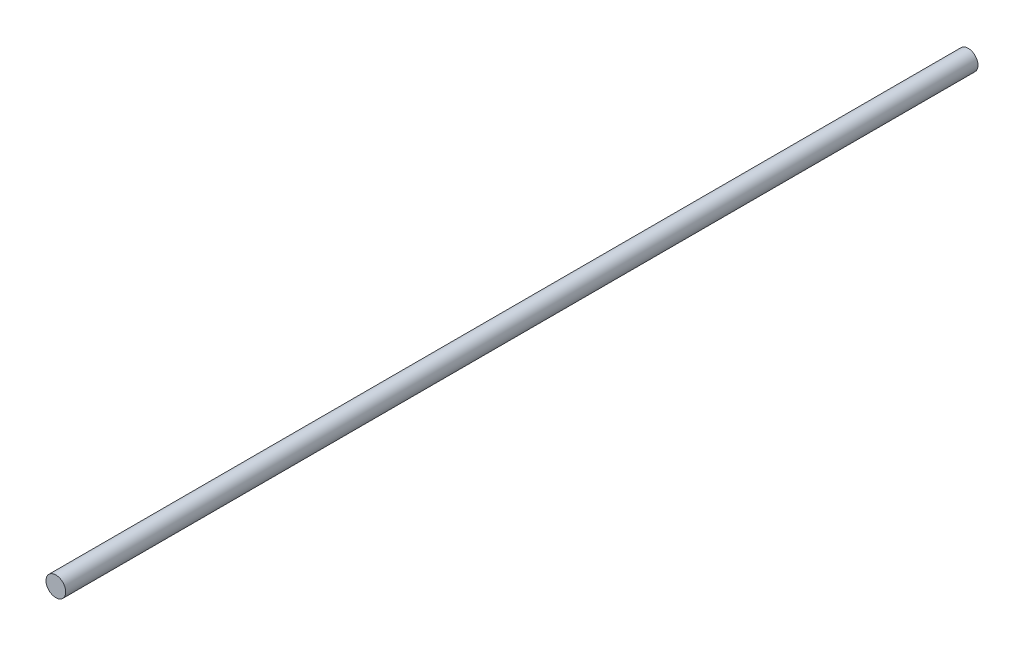
from build123d import *

# Parameters (mm, degrees)
SKETCH1_R           = 4
BOSS_EXTRUDE1_DEPTH = 370


with BuildPart() as part:
    # Sketch1 → Boss-Extrude1 (new body)
    with BuildSketch(Plane.XY):
        Circle(SKETCH1_R)
    extrude(amount=BOSS_EXTRUDE1_DEPTH)


solid = part.part
